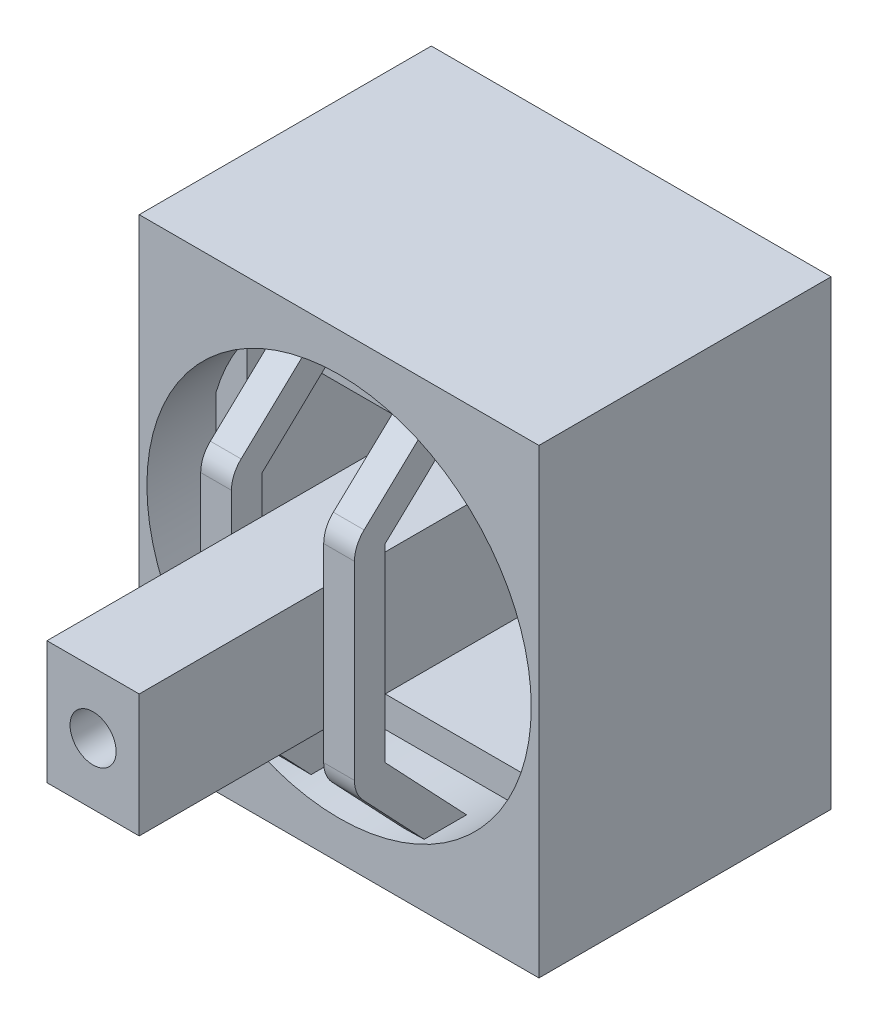
from build123d import *

# Parameters (mm, degrees)
ESBO_O1_W                     = 13
ESBO_O1_H                     = 15
RESSALTO_EXTRUS_O1_DEPTH      = 9.5
ESBO_O3_R                     = 6.25
CORTE_EXTRUS_O1_DEPTH         = 10.5
ESBO_O2_W                     = 3
ESBO_O2_H                     = 4
ESBO_O2_R                     = 0.75
RESSALTO_EXTRUS_O2_DEPTH      = 8
RESSALTO_EXTRUS_O2_DEPTH_BACK = 9.5
RESSALTO_EXTRUS_O3_DEPTH      = 1.5
ESBO_O5_W                     = 12
ESBO_O5_H                     = 10
ESBO_O5_W_2                   = 10
ESBO_O5_H_2                   = 8
RESSALTO_EXTRUS_O4_DEPTH      = 7.5
RESSALTO_EXTRUS_O5_DEPTH      = 1
FILETE1_R                     = 1


with BuildPart() as part:
    # Esboço1 → Ressalto-extrusão1 (new body)
    with BuildSketch(Plane.XY):
        Rectangle(ESBO_O1_W, ESBO_O1_H)
    extrude(amount=-RESSALTO_EXTRUS_O1_DEPTH)

    # Esboço3 → Corte-extrusão1 (cut, through all)
    with BuildSketch(Plane.XY):
        Circle(ESBO_O3_R)
    extrude(amount=-CORTE_EXTRUS_O1_DEPTH, mode=Mode.SUBTRACT)

    # Esboço4 → Ressalto-extrusão3 (add)
    with BuildSketch(Plane.ZY.offset(6.5)):
        Polygon((-6.5, 2.25), (-6.5, -1.75), (-4.849272887, -0.75), (-4.849272887, 1.25), align=None)
    extrude(amount=RESSALTO_EXTRUS_O3_DEPTH)

    # Esboço5 → Ressalto-extrusão4 (add)
    with BuildSketch(Plane(origin=(0, 0, -9.5), x_dir=(-1, 0, 0), z_dir=(0, 0, -1))):
        Rectangle(ESBO_O5_W, ESBO_O5_H)
        Rectangle(ESBO_O5_W_2, ESBO_O5_H_2, mode=Mode.SUBTRACT)
    extrude(amount=-RESSALTO_EXTRUS_O4_DEPTH)



with BuildPart() as body_2:
    # Esboço2 → Ressalto-extrusão2 (new body, two sides)
    with BuildSketch(Plane.XY) as ressalto_extrus_o2_sk:
        Rectangle(ESBO_O2_W, ESBO_O2_H)
        Circle(ESBO_O2_R, mode=Mode.SUBTRACT)
    extrude(amount=RESSALTO_EXTRUS_O2_DEPTH)
    extrude(ressalto_extrus_o2_sk.sketch, amount=-RESSALTO_EXTRUS_O2_DEPTH_BACK)


with BuildPart() as part_1:
    add(part.part)

    add(body_2.part)  # Ressalto-extrusão5 merges body 2
    # Esboço6 → Ressalto-extrusão5 (add)
    with BuildSketch(Plane.ZY.offset(1.5)):
        Polygon((-1, 7.5), (-1, 6.5), (2, 3.667217521), (2, -3.332782479), (-1, -6.5), (-1, -7.5), (-2, -7.5), (-2, -6.101577834), (1, -2.934360312), (1, 3.236113484), (-2, 6.068895963), (-2, 7.5), align=None)
    ressalto_extrus_o5 = extrude(amount=RESSALTO_EXTRUS_O5_DEPTH)

    # Espelhar1: Ressalto-extrusão5 across plane
    add(ressalto_extrus_o5.mirror(Plane(origin=(0, 0, 0), x_dir=(0, 0, 1), z_dir=(1, 0, 0))))

    # Filete1
    filete1_edges = [part_1.edges().sort_by_distance(p)[0] for p in [
        (2, -3.332782479, 2),
        (2, 3.667217521, 2),
        (-2, -3.332782479, 2),
        (-2, 3.667217521, 2),
    ]]
    fillet(filete1_edges, radius=FILETE1_R)


solid = part_1.part
